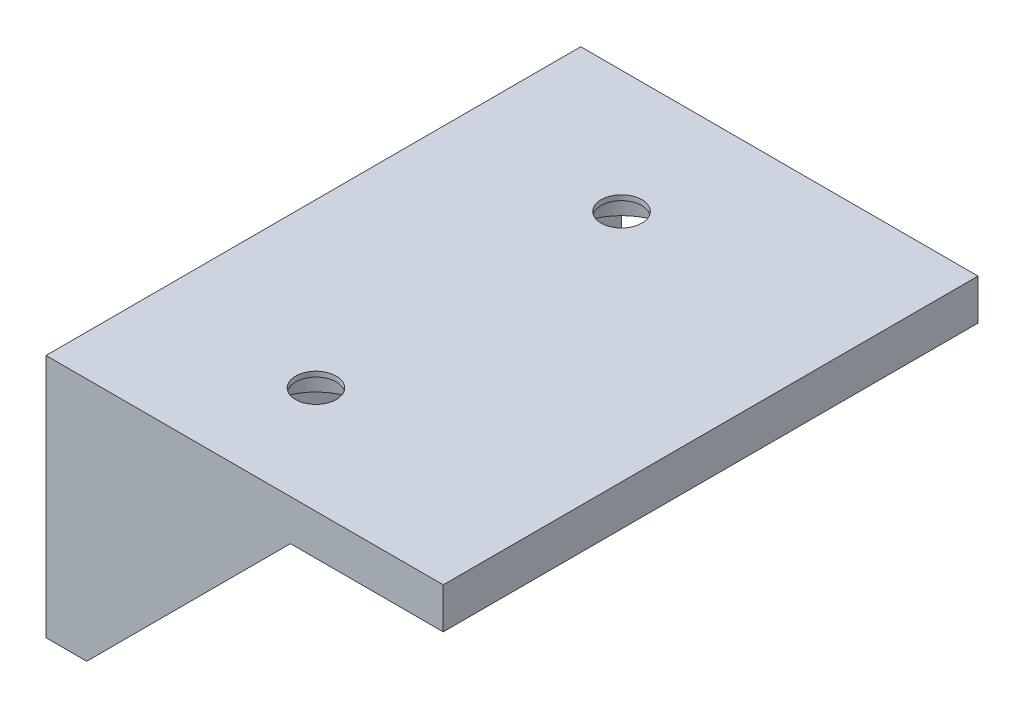
from build123d import *

# Parameters (mm, degrees)
RESSALTO_EXTRUS_O1_DEPTH = 50
ESBO_O2_R                = 5.15
CORTE_EXTRUS_O1_DEPTH    = 3.5
ESBO_O3_R                = 5.15
CORTE_EXTRUS_O2_DEPTH    = 3.5
RESSALTO_EXTRUS_O2_DEPTH = 2.5
ESBO_O5_R                = 2
CORTE_EXTRUS_O3_DEPTH    = 10
ESBO_O6_R                = 2
CORTE_EXTRUS_O4_DEPTH    = 10


with BuildPart() as part:
    # Esboço1 → Ressalto-extrusão1 (new body)
    with BuildSketch(Plane.XY):
        Polygon((0, 0), (35, 0), (35, 4), (-4, 4), (-4, -20), (0, -20), align=None)
    extrude(amount=RESSALTO_EXTRUS_O1_DEPTH)

    # Esboço2 → Corte-extrusão1 (cut)
    with BuildSketch(Plane(origin=(0, 0, 0), x_dir=(0, 0, -1), z_dir=(1, 0, 0))):
        with Locations((-42, -12)):
            Circle(ESBO_O2_R)
        with Locations((-12, -12)):
            Circle(ESBO_O2_R)
    extrude(amount=-CORTE_EXTRUS_O1_DEPTH, mode=Mode.SUBTRACT)

    # Esboço3 → Corte-extrusão2 (cut)
    with BuildSketch(Plane.XZ):
        with Locations((12, 42)):
            Circle(ESBO_O3_R)
        with Locations((12, 12)):
            Circle(ESBO_O3_R)
    extrude(amount=-CORTE_EXTRUS_O2_DEPTH, mode=Mode.SUBTRACT)

    # Esboço4 → Ressalto-extrusão2 (add)
    with BuildSketch(Plane.XY.offset(50)):
        Polygon((0, -20), (20, 0), (35, 0), (35, 4), (-4, 4), (-4, -20), align=None)
    extrude(amount=RESSALTO_EXTRUS_O2_DEPTH)

    # Esboço5 → Corte-extrusão3 (cut)
    with BuildSketch(Plane.XZ.offset(-3.5)):
        with Locations((12, 42)):
            Circle(ESBO_O5_R)
        with Locations((12, 12)):
            Circle(ESBO_O5_R)
    extrude(amount=-CORTE_EXTRUS_O3_DEPTH, mode=Mode.SUBTRACT)

    # Esboço6 → Corte-extrusão4 (cut)
    with BuildSketch(Plane(origin=(-3.5, 0, 0), x_dir=(0, 0, -1), z_dir=(1, 0, 0))):
        with Locations((-42, -12)):
            Circle(ESBO_O6_R)
        with Locations((-12, -12)):
            Circle(ESBO_O6_R)
    extrude(amount=-CORTE_EXTRUS_O4_DEPTH, mode=Mode.SUBTRACT)


solid = part.part
